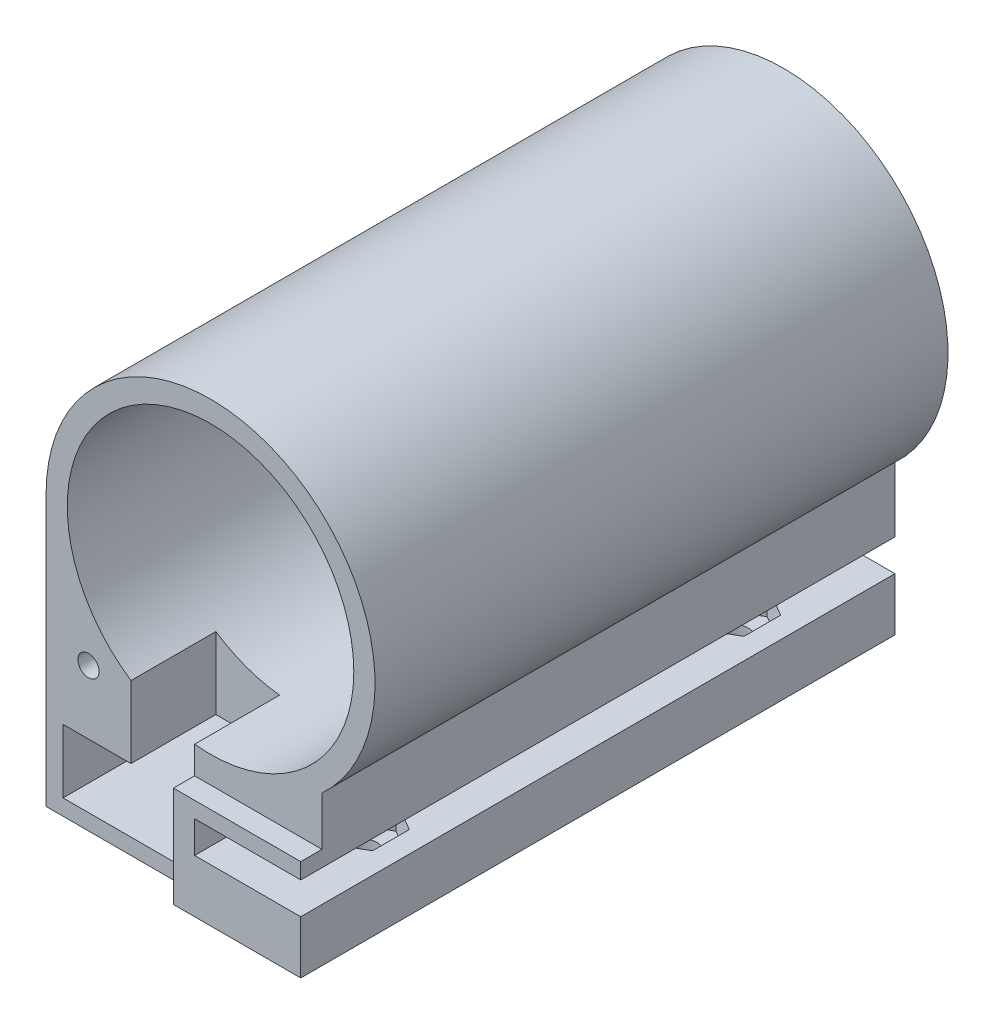
from build123d import *

# Parameters (mm, degrees)
ESBO_O1_R                = 4.5
RESSALTO_EXTRUS_O1_DEPTH = 28
CORTE_EXTRUS_O5_START    = 28
ESBO_O1_3_R              = 13.5
ESBO_O1_3_W              = 12.4
ESBO_O1_3_H              = 6
CORTE_EXTRUS_O5_DEPTH    = 54
ESBO_O3_R                = 1
CORTE_EXTRUS_O3_DEPTH    = 10
CORTE_EXTRUS_O4_DEPTH    = 2
ESBO_O5_R                = 1.65
CORTE_EXTRUS_O6_DEPTH    = 2.5
ESBO_O5_2_R              = 1.65
CORTE_EXTRUS_O7_DEPTH    = 6
ESBO_O6_W                = 5
ESBO_O6_H                = 3
CORTE_EXTRUS_O8_DEPTH    = 3


with BuildPart() as part:
    # Esboço1 → Ressalto-extrusão1 (new body, symmetric)
    with BuildSketch(Plane.XY):
        with BuildLine():
            Line((-16, 0), (-16, -25.5))
            Line((-16, -25.5), (10, -25.5))
            Line((10, -25.5), (10, -20.5))
            Line((10, -20.5), (0, -20.5))
            Line((0, -20.5), (0, -17.5))
            Line((0, -17.5), (10, -17.5))
            Line((10, -17.5), (10, -11.401754251))
            ThreePointArc((10, -11.401754251), (5.724949799, 14.195069567), (-16, 0))
        make_face()
        with Locations((-0.5, 0)):
            Circle(ESBO_O1_R, mode=Mode.SUBTRACT)
        with BuildLine():
            Line((-2.2, 8), (-2.2, 11))
            ThreePointArc((-2.2, 11), (-0.5, 12.7), (1.2, 11))
            Line((1.2, 11), (1.2, 8))
            ThreePointArc((1.2, 8), (-0.5, 6.3), (-2.2, 8))
        make_face(mode=Mode.SUBTRACT)
        with BuildLine():
            Line((-2.2, -8), (-2.2, -11))
            ThreePointArc((-2.2, -11), (-0.5, -12.7), (1.2, -11))
            Line((1.2, -11), (1.2, -8))
            ThreePointArc((1.2, -8), (-0.5, -6.3), (-2.2, -8))
        make_face(mode=Mode.SUBTRACT)
    extrude(amount=RESSALTO_EXTRUS_O1_DEPTH, both=True)

    # Esboço1<3> → Corte-extrusão5 (cut)
    with BuildSketch(Plane.XY.offset(CORTE_EXTRUS_O5_START)):
        with Locations((-0.5, 0)):
            Circle(ESBO_O1_3_R)
        with Locations((-8.2, -21)):
            Rectangle(ESBO_O1_3_W, ESBO_O1_3_H)
    extrude(amount=-CORTE_EXTRUS_O5_DEPTH, mode=Mode.SUBTRACT)

    # Esboço3 → Corte-extrusão3 (cut)
    with BuildSketch(Plane.XY.offset(28)):
        with Locations((-12, -12)):
            Circle(ESBO_O3_R)
        Polygon((-8, -11.22497216), (-8, -18), (-2, -18), (-2, -13.416407865), align=None)
    extrude(amount=-CORTE_EXTRUS_O3_DEPTH, mode=Mode.SUBTRACT)

    # Esboço4 → Corte-extrusão4 (cut)
    with BuildSketch(Plane.XY.offset(28)):
        with BuildLine():
            Line((-2, -25.5), (-16, -25.5))
            Line((-16, -25.5), (-16, 0))
            ThreePointArc((-16, 0), (5.724949799, 14.195069567), (10, -11.401754251))
            Line((10, -11.401754251), (10, -16))
            Line((10, -16), (-2, -16))
            Line((-2, -16), (-2, -25.5))
        make_face()
    extrude(amount=-CORTE_EXTRUS_O4_DEPTH, mode=Mode.SUBTRACT)

    # Esboço5 → Corte-extrusão6 (cut)
    with BuildSketch(Plane(origin=(0, -20.5, 0), x_dir=(1, 0, 0), z_dir=(0, 1, 0))):
        Polygon((5, 14.035898385), (8, 15.767949192), (8, 19.232050808), (5, 20.964101615), (2, 19.232050808), (2, 15.767949192), align=None)
        with Locations((5, 17.5)):
            Circle(ESBO_O5_R, mode=Mode.SUBTRACT)
        Polygon((5, -20.964101615), (8, -19.232050808), (8, -15.767949192), (5, -14.035898385), (2, -15.767949192), (2, -19.232050808), align=None)
        with Locations((5, -17.5)):
            Circle(ESBO_O5_R, mode=Mode.SUBTRACT)
    extrude(amount=-CORTE_EXTRUS_O6_DEPTH, mode=Mode.SUBTRACT)

    # Esboço5<2> → Corte-extrusão7 (cut, through all)
    with BuildSketch(Plane(origin=(0, -20.5, 0), x_dir=(1, 0, 0), z_dir=(0, 1, 0))):
        with Locations((5, -17.5)):
            Circle(ESBO_O5_2_R)
        with Locations((5, 17.5)):
            Circle(ESBO_O5_2_R)
    extrude(amount=-CORTE_EXTRUS_O7_DEPTH, mode=Mode.SUBTRACT)

    # Esboço6 → Corte-extrusão8 (cut, through all)
    with BuildSketch(Plane.XY.offset(-26)):
        with Locations((-11.9, -22.5)):
            Rectangle(ESBO_O6_W, ESBO_O6_H)
    extrude(amount=-CORTE_EXTRUS_O8_DEPTH, mode=Mode.SUBTRACT)


solid = part.part
